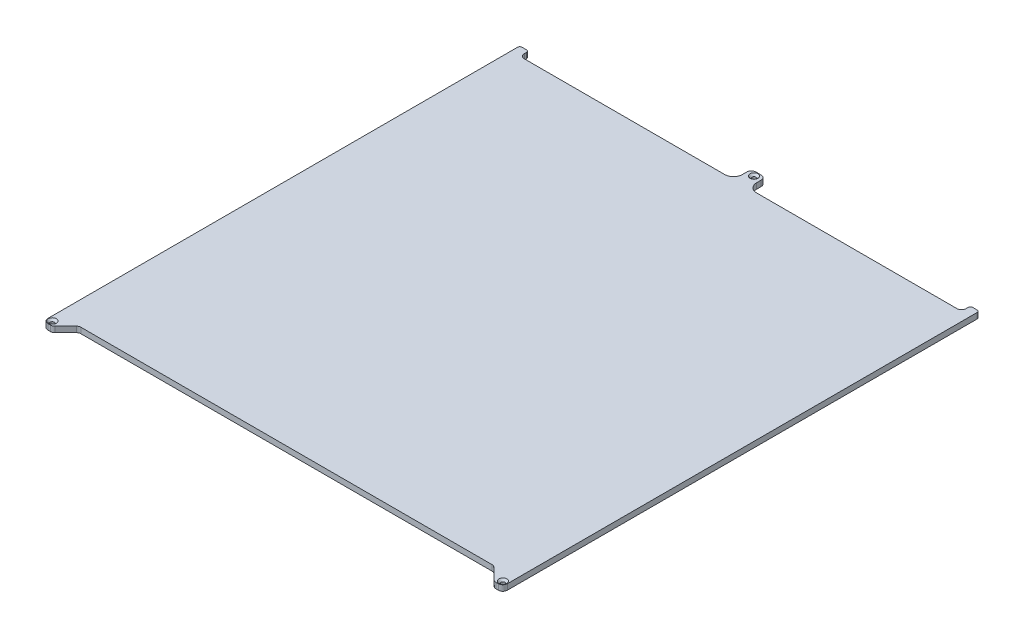
from build123d import *

# Parameters (mm, degrees)
BOSS_EXTRUDE1_DEPTH           = 6.35
CSK_FOR_M4_SFHCS1_D           = 4.5
CSK_FOR_M4_SFHCS1_CSINK_D     = 8.96
CSK_FOR_M4_SFHCS1_CSINK_ANGLE = 90


with BuildPart() as part:
    # Sketch1 → Boss-Extrude1 (new body)
    with BuildSketch(Plane(origin=(0, 0, 0), x_dir=(1, 0, 0), z_dir=(0, 1, 0))):
        with BuildLine():
            Line((230.928932188, -255), (-230.928932188, -255))
            ThreePointArc((-230.928932188, -255), (-232.84234935, -255.380602337), (-234.464466094, -256.464466094))
            Line((-234.464466094, -256.464466094), (-246.535533906, -268.535533906))
            ThreePointArc((-246.535533906, -268.535533906), (-248.15765065, -269.619397663), (-250.071067812, -270))
            Line((-250.071067812, -270), (-253, -270))
            ThreePointArc((-253, -270), (-256.535533906, -268.535533906), (-258, -265))
            Line((-258, -265), (-258, 262.5))
            ThreePointArc((-258, 262.5), (-257.267766953, 264.267766953), (-255.5, 265))
            Line((-255.5, 265), (-250.5, 265))
            ThreePointArc((-250.5, 265), (-248.732233047, 264.267766953), (-248, 262.5))
            Line((-248, 262.5), (-248, 260))
            ThreePointArc((-248, 260), (-246.535533906, 256.464466094), (-243, 255))
            Line((-243, 255), (-18, 255))
            ThreePointArc((-18, 255), (-10.928932188, 257.928932188), (-8, 265))
            Line((-8, 265), (-8, 270))
            ThreePointArc((-8, 270), (-6.535533906, 273.535533906), (-3, 275))
            Line((-3, 275), (3, 275))
            ThreePointArc((3, 275), (6.535533906, 273.535533906), (8, 270))
            Line((8, 270), (8, 265))
            ThreePointArc((8, 265), (10.928932188, 257.928932188), (18, 255))
            Line((18, 255), (243, 255))
            ThreePointArc((243, 255), (246.535533906, 256.464466094), (248, 260))
            Line((248, 260), (248, 262.5))
            ThreePointArc((248, 262.5), (248.732233047, 264.267766953), (250.5, 265))
            Line((250.5, 265), (255.5, 265))
            ThreePointArc((255.5, 265), (257.267766953, 264.267766953), (258, 262.5))
            Line((258, 262.5), (258, -265))
            ThreePointArc((258, -265), (256.535533906, -268.535533906), (253, -270))
            Line((253, -270), (250.071067812, -270))
            ThreePointArc((250.071067812, -270), (248.15765065, -269.619397663), (246.535533906, -268.535533906))
            Line((246.535533906, -268.535533906), (234.464466094, -256.464466094))
            ThreePointArc((234.464466094, -256.464466094), (232.84234935, -255.380602337), (230.928932188, -255))
        make_face()
    extrude(amount=BOSS_EXTRUDE1_DEPTH)

    # CSK for M4 SFHCS1 (through all)
    with Locations(Plane(origin=(0, 6.35, 0), x_dir=(1, 0, 0), z_dir=(0, 1, 0))):
        with Locations((0, 270), (253, -265), (-253, -265)):
            CounterSinkHole(CSK_FOR_M4_SFHCS1_D / 2, CSK_FOR_M4_SFHCS1_CSINK_D / 2, counter_sink_angle=CSK_FOR_M4_SFHCS1_CSINK_ANGLE)


solid = part.part
